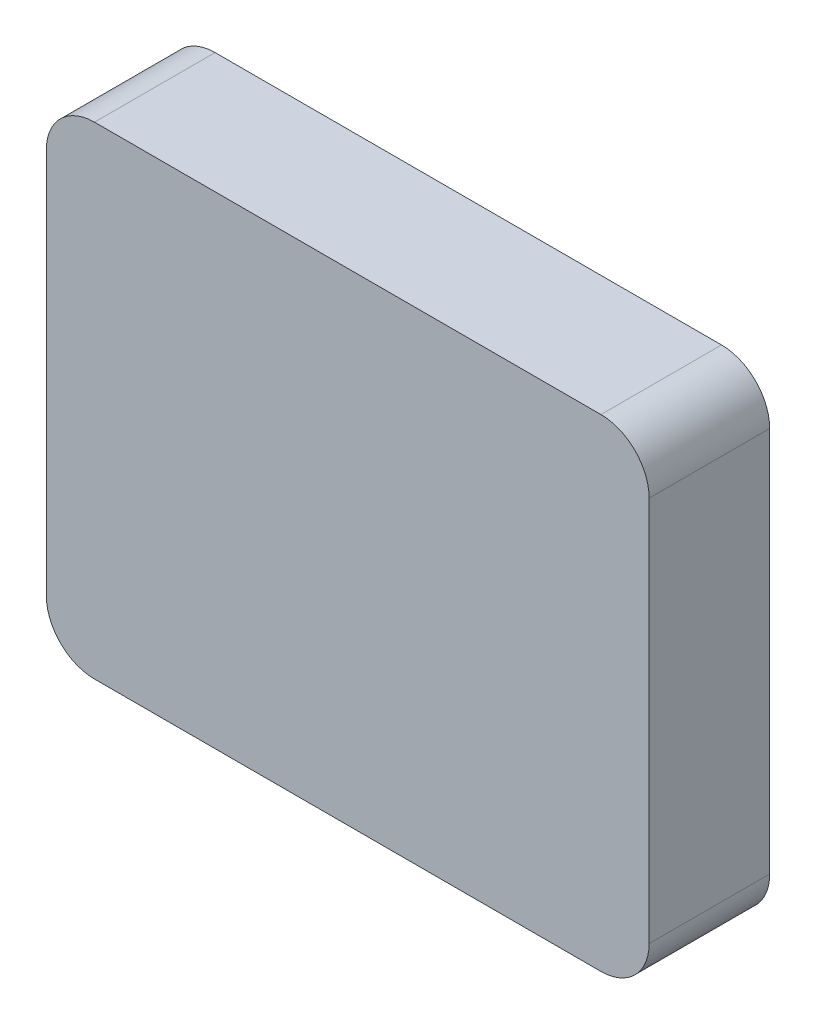
from build123d import *

# Parameters (mm, degrees)
SKETCH1_W           = 250
SKETCH1_H           = 200
BOSS_EXTRUDE1_DEPTH = 25
FILLET1_R           = 20


with BuildPart() as part:
    # Sketch1 → Boss-Extrude1 (new body, symmetric)
    with BuildSketch(Plane.XY):
        Rectangle(SKETCH1_W, SKETCH1_H)
    extrude(amount=BOSS_EXTRUDE1_DEPTH, both=True)

    # Fillet1
    fillet1_edges = [part.edges().sort_by_distance(p)[0] for p in [
        (125, -100, 0),
        (-125, -100, 0),
        (-125, 100, 0),
        (125, 100, 0),
    ]]
    fillet(fillet1_edges, radius=FILLET1_R)


solid = part.part
